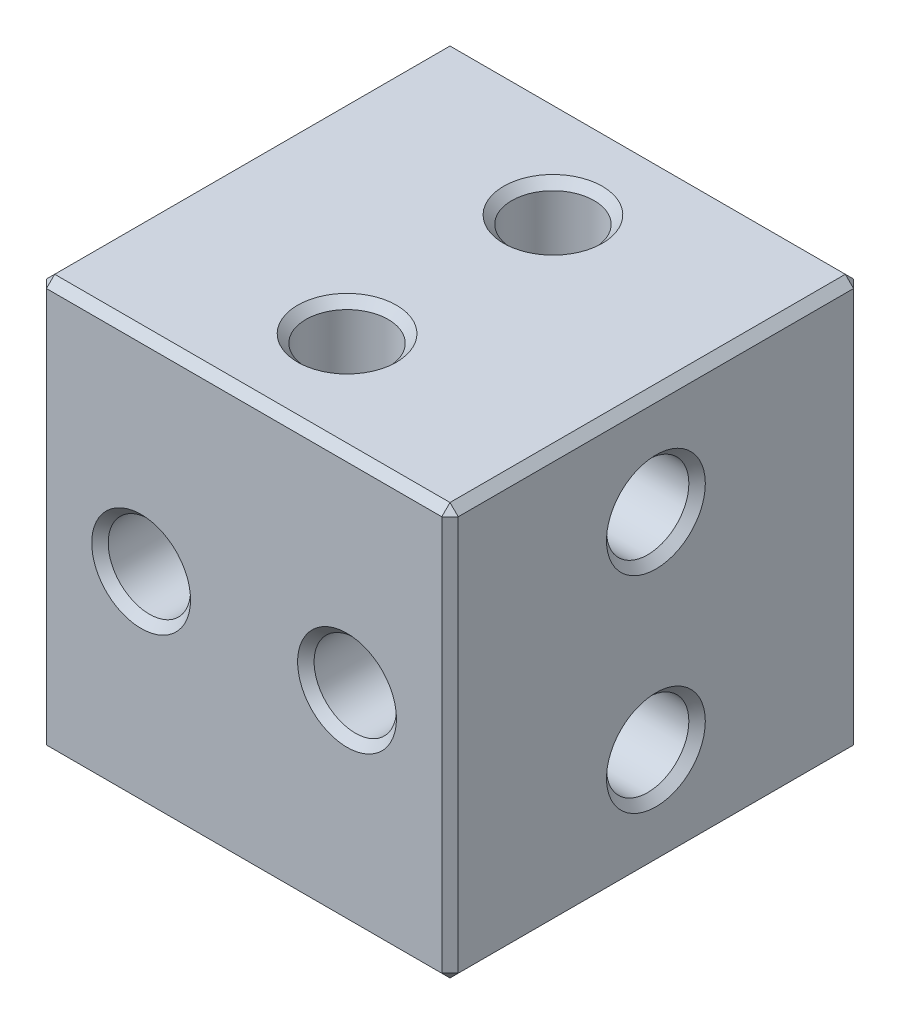
from build123d import *

# Parameters (mm, degrees)
SKETCH1_W           = 10
SKETCH1_H           = 10
BOSS_EXTRUDE1_DEPTH = 10
SKETCH2_R           = 1
CUT_EXTRUDE1_DEPTH  = 11
SKETCH3_R           = 1
CUT_EXTRUDE2_DEPTH  = 11
SKETCH5_R           = 1
CUT_EXTRUDE4_DEPTH  = 11
CHAMFER1_SIZE       = 0.2
CHAMFER2_SIZE       = 0.2


with BuildPart() as part:
    # Sketch1 → Boss-Extrude1 (new body)
    with BuildSketch(Plane.XY):
        Rectangle(SKETCH1_W, SKETCH1_H)
    extrude(amount=BOSS_EXTRUDE1_DEPTH)

    # Sketch2 → Cut-Extrude1 (cut, through all)
    with BuildSketch(Plane.XY.offset(10)):
        with Locations((-2.5, 0)):
            Circle(SKETCH2_R)
        with Locations(Location((2.5, 0, 0), (0, 0, 180))):  # turned: the seam where the file's is
            Circle(SKETCH2_R)
    extrude(amount=-CUT_EXTRUDE1_DEPTH, mode=Mode.SUBTRACT)

    # Sketch3 → Cut-Extrude2 (cut, through all)
    with BuildSketch(Plane(origin=(0, 5, 0), x_dir=(1, 0, 0), z_dir=(0, 1, 0))):
        with Locations(Location((0, -7.5, 0), (0, 0, 90))):  # turned: the seam where the file's is
            Circle(SKETCH3_R)
        with Locations(Location((0, -2.5, 0), (0, 0, 270))):  # turned: the seam where the file's is
            Circle(SKETCH3_R)
    extrude(amount=-CUT_EXTRUDE2_DEPTH, mode=Mode.SUBTRACT)

    # Sketch5 → Cut-Extrude4 (cut, through all)
    with BuildSketch(Plane(origin=(5, 0, 0), x_dir=(0, 0, -1), z_dir=(1, 0, 0))):
        with Locations(Location((-5, 2.5, 0), (0, 0, 90))):  # turned: the seam where the file's is
            Circle(SKETCH5_R)
        with Locations(Location((-5, -2.5, 0), (0, 0, 270))):  # turned: the seam where the file's is
            Circle(SKETCH5_R)
    extrude(amount=-CUT_EXTRUDE4_DEPTH, mode=Mode.SUBTRACT)

    # Chamfer1
    chamfer1_edges = [part.edges().sort_by_distance(p)[0] for p in [
        (5, 0, 10),
        (0, 5, 10),
        (-5, 0, 10),
        (0, 5, 0),
        (5, 0, 0),
        (0, -5, 0),
        (-5, 0, 0),
        (0, -5, 10),
        (-5, 5, 5),
        (5, 5, 5),
        (5, -5, 5),
        (-5, -5, 5),
    ]]
    chamfer(chamfer1_edges, length=CHAMFER1_SIZE)

    # Chamfer2
    chamfer2_edges = [part.edges().sort_by_distance(p)[0] for p in [
        (-3.5, 0, 0),
        (-3.5, 0, 10),
        (3.5, 0, 0),
        (3.5, 0, 10),
        (0, -5, 8.5),
        (0, 5, 8.5),
        (0, -5, 1.5),
        (0, 5, 1.5),
        (-5, 1.5, 5),
        (5, 1.5, 5),
        (-5, -1.5, 5),
        (5, -1.5, 5),
    ]]
    chamfer(chamfer2_edges, length=CHAMFER2_SIZE)


solid = part.part
